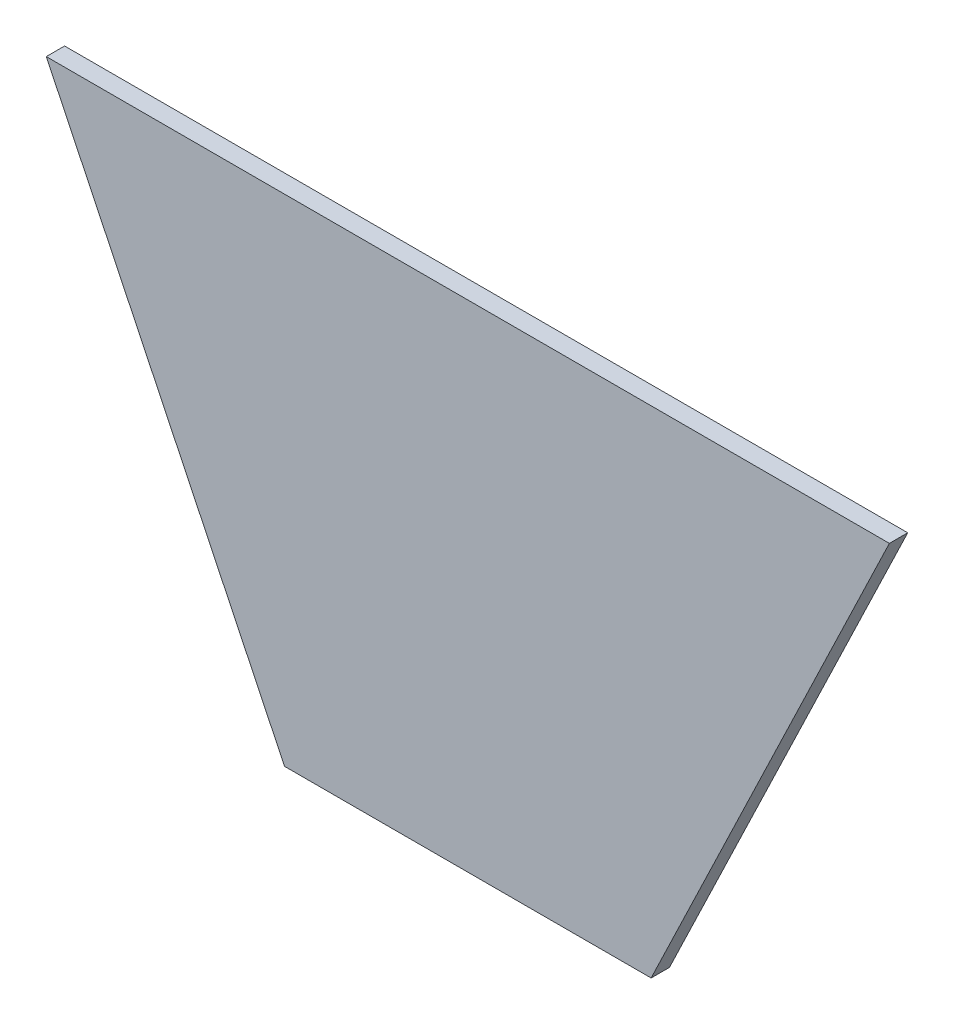
from build123d import *

# Parameters (mm, degrees)
BOSS_EXTRUDE1_DEPTH = 10


with BuildPart() as part:
    # Sketch1 → Boss-Extrude1 (new body)
    with BuildSketch(Plane.XY):
        Polygon((-100, 0), (100, 0), (230, 270.370116692), (-230, 270.370116692), align=None)
    extrude(amount=BOSS_EXTRUDE1_DEPTH)


solid = part.part
